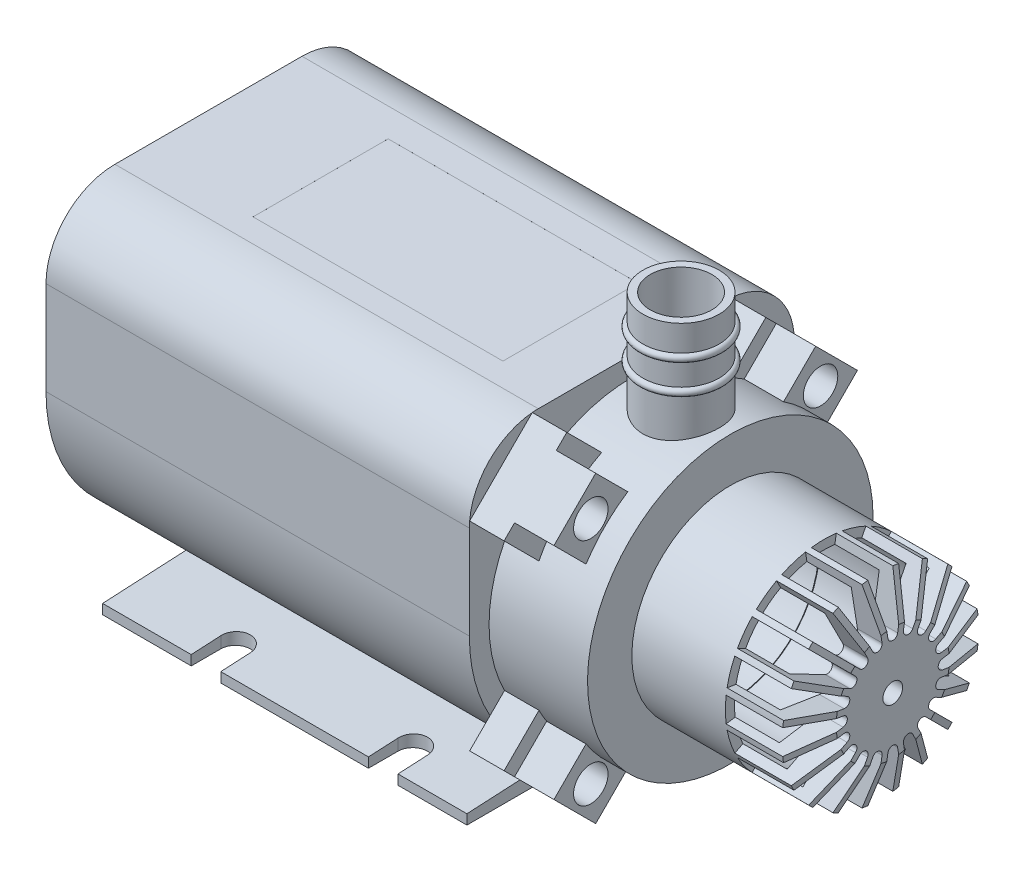
from build123d import *

# Parameters (mm, degrees)
BOSS_EXTRU_1_DEPTH           = 43
ESQUISSE2_R                  = 3.25
ENL_V_MAT_EXTRU_1_DEPTH      = 8
ESQUISSE3_R                  = 14.5
ESQUISSE3_R_2                = 9
BOSS_EXTRU_2_DEPTH           = 10
ESQUISSE4_R                  = 10
BOSS_EXTRU_3_DEPTH           = 16.5
ESQUISSE7_R                  = 1
ENL_V_MAT_EXTRU_2_DEPTH      = 10
ENL_V_MAT_EXTRU_3_DEPTH      = 7
ESQUISSE10_R                 = 9.079731565
ENL_V_MAT_EXTRU_4_DEPTH      = 14
BOSS_EXTRU_4_DEPTH           = 37
ENL_V_MAT_EXTRU_5_REACH      = 84.412
BOSS_EXTRU_5_DEPTH           = 3.5
BOSS_EXTRU_6_DEPTH           = 4
ESQUISSE16_R                 = 1.75
ENL_V_MAT_EXTRU_6_DEPTH      = 3
R_P_TITION_CIRCULAIRE1_COUNT = 4
ESQUISSE17_R                 = 13.283014913
ENL_V_MAT_EXTRU_7_DEPTH      = 31
ESQUISSE18_W                 = 25.376339854
ESQUISSE18_H                 = 13.72140852
ENL_V_MAT_EXTRU_8_DEPTH      = 0.001
ESQUISSE19_W                 = 1.346153846
ESQUISSE19_H                 = 0.358974359
ENL_V_MAT_EXTRU_9_DEPTH      = 0.01
ESQUISSE20_R                 = 2
ENL_V_MAT_EXTRU_10_DEPTH     = 0.01


with BuildPart() as part:
    # Esquisse1 → Boss.-Extru.1 (new body)
    with BuildSketch(Plane(origin=(0, 0, 0), x_dir=(0, 0, -1), z_dir=(1, 0, 0))):
        with BuildLine():
            Line((-16.5, 0), (-16.5, 9.5))
            ThreePointArc((-16.5, 9.5), (-14.449747468, 14.449747468), (-9.5, 16.5))
            Line((-9.5, 16.5), (9.5, 16.5))
            ThreePointArc((9.5, 16.5), (14.449747468, 14.449747468), (16.5, 9.5))
            Line((16.5, 9.5), (16.5, 0))
            ThreePointArc((16.5, 0), (0, -16.5), (-16.5, 0))
        make_face()
    extrude(amount=BOSS_EXTRU_1_DEPTH)

    # Esquisse2 → Enlèv. mat.-Extru.1 (cut)
    with BuildSketch(Plane.ZY):
        with Locations((0, -6.5)):
            Circle(ESQUISSE2_R)
    extrude(amount=-ENL_V_MAT_EXTRU_1_DEPTH, mode=Mode.SUBTRACT)

    # Esquisse3 → Boss.-Extru.2 (add)
    with BuildSketch(Plane(origin=(43, 0, 0), x_dir=(0, 0, -1), z_dir=(1, 0, 0))):
        Circle(ESQUISSE3_R)
        Circle(ESQUISSE3_R_2, mode=Mode.SUBTRACT)
    extrude(amount=BOSS_EXTRU_2_DEPTH)

    # Esquisse4 → Boss.-Extru.3 (add)
    with BuildSketch(Plane(origin=(53, 0, 0), x_dir=(0, 0, -1), z_dir=(1, 0, 0))):
        Circle(ESQUISSE4_R)
    extrude(amount=BOSS_EXTRU_3_DEPTH)

    # Esquisse6 → Révolution1 (revolve)
    with BuildSketch(Plane.XY):
        with BuildLine():
            Line((51.875, 10), (51.875, 18.125))
            ThreePointArc((51.875, 18.125), (52.25, 18.5), (51.875, 18.875))
            Line((51.875, 18.875), (51.875, 21.125))
            ThreePointArc((51.875, 21.125), (52.25, 21.5), (51.875, 21.875))
            Line((51.875, 21.875), (51.875, 24.5))
            Line((51.875, 24.5), (51.125, 24.5))
            Line((51.125, 24.5), (51.125, 10))
            Line((51.125, 10), (51.875, 10))
        make_face()
    revolve(axis=Axis((48, -3.633595293, 0), (0, 1, 0)))

    # Esquisse7 → Enlèv. mat.-Extru.2 (cut)
    with BuildSketch(Plane(origin=(69.5, 0, 0), x_dir=(0, 0, -1), z_dir=(1, 0, 0))):
        Circle(ESQUISSE7_R)
    extrude(amount=-ENL_V_MAT_EXTRU_2_DEPTH, mode=Mode.SUBTRACT)

    # Esquisse8 → Enlèv. mat.-Extru.3 (cut)
    with BuildSketch(Plane(origin=(69.5, 0, 0), x_dir=(0, 0, -1), z_dir=(1, 0, 0))):
        with BuildLine():
            Line((-9.384278831, 4.444831018), (-4.636672183, 2.025804607))
            ThreePointArc((-4.636672183, 2.025804607), (-4.388139175, 1.425792848), (-4.941884666, 1.086457175))
            Line((-4.941884666, 1.086457175), (-10.204647176, 1.919996869))
            ThreePointArc((-10.204647176, 1.919996869), (-9.87548492, 3.20873956), (-9.384278831, 4.444831018))
        make_face()
        with BuildLine():
            Line((-10.298507855, 1.327383865), (-5.035745345, 0.49384417))
            ThreePointArc((-5.035745345, 0.49384417), (-4.613962577, 0), (-5.035745345, -0.49384417))
            Line((-5.035745345, -0.49384417), (-10.298507855, -1.327383865))
            ThreePointArc((-10.298507855, -1.327383865), (-10.383699339, 0), (-10.298507855, 1.327383865))
        make_face()
        with BuildLine():
            Line((-7.551451211, 7.127187143), (-3.783729243, 3.359465174))
            ThreePointArc((-3.783729243, 3.359465174), (-3.732774136, 2.712019158), (-4.364277883, 2.560408522))
            Line((-4.364277883, 2.560408522), (-9.111884531, 4.979434933))
            ThreePointArc((-9.111884531, 4.979434933), (-8.40058923, 6.103385336), (-7.551451211, 7.127187143))
        make_face()
        with BuildLine():
            Line((-4.979434933, 9.111884531), (-2.560408522, 4.364277883))
            ThreePointArc((-2.560408522, 4.364277883), (-2.712019158, 3.732774136), (-3.359465174, 3.783729243))
            Line((-3.359465174, 3.783729243), (-7.127187143, 7.551451211))
            ThreePointArc((-7.127187143, 7.551451211), (-6.103385336, 8.40058923), (-4.979434933, 9.111884531))
        make_face()
        with BuildLine():
            Line((-1.919996869, 10.204647176), (-1.086457175, 4.941884666))
            ThreePointArc((-1.086457175, 4.941884666), (-1.425792848, 4.388139175), (-2.025804607, 4.636672183))
            Line((-2.025804607, 4.636672183), (-4.444831018, 9.384278831))
            ThreePointArc((-4.444831018, 9.384278831), (-3.20873956, 9.87548492), (-1.919996869, 10.204647176))
        make_face()
        with BuildLine():
            Line((1.327383865, 10.298507855), (0.49384417, 5.035745345))
            ThreePointArc((0.49384417, 5.035745345), (0, 4.613962577), (-0.49384417, 5.035745345))
            Line((-0.49384417, 5.035745345), (-1.327383865, 10.298507855))
            ThreePointArc((-1.327383865, 10.298507855), (0, 10.383699339), (1.327383865, 10.298507855))
        make_face()
        with BuildLine():
            Line((4.444831018, 9.384278831), (2.025804607, 4.636672183))
            ThreePointArc((2.025804607, 4.636672183), (1.425792848, 4.388139175), (1.086457175, 4.941884666))
            Line((1.086457175, 4.941884666), (1.919996869, 10.204647176))
            ThreePointArc((1.919996869, 10.204647176), (3.20873956, 9.87548492), (4.444831018, 9.384278831))
        make_face()
        with BuildLine():
            Line((7.127187143, 7.551451211), (3.359465174, 3.783729243))
            ThreePointArc((3.359465174, 3.783729243), (2.712019158, 3.732774136), (2.560408522, 4.364277883))
            Line((2.560408522, 4.364277883), (4.979434933, 9.111884531))
            ThreePointArc((4.979434933, 9.111884531), (6.103385336, 8.40058923), (7.127187143, 7.551451211))
        make_face()
        with BuildLine():
            Line((9.111884531, 4.979434933), (4.364277883, 2.560408522))
            ThreePointArc((4.364277883, 2.560408522), (3.732774136, 2.712019158), (3.783729243, 3.359465174))
            Line((3.783729243, 3.359465174), (7.551451211, 7.127187143))
            ThreePointArc((7.551451211, 7.127187143), (8.40058923, 6.103385336), (9.111884531, 4.979434933))
        make_face()
        with BuildLine():
            Line((10.204647176, 1.919996869), (4.941884666, 1.086457175))
            ThreePointArc((4.941884666, 1.086457175), (4.388139175, 1.425792848), (4.636672183, 2.025804607))
            Line((4.636672183, 2.025804607), (9.384278831, 4.444831018))
            ThreePointArc((9.384278831, 4.444831018), (9.87548492, 3.20873956), (10.204647176, 1.919996869))
        make_face()
        with BuildLine():
            Line((10.298507855, -1.327383865), (5.035745345, -0.49384417))
            ThreePointArc((5.035745345, -0.49384417), (4.613962577, 0), (5.035745345, 0.49384417))
            Line((5.035745345, 0.49384417), (10.298507855, 1.327383865))
            ThreePointArc((10.298507855, 1.327383865), (10.383699339, 0), (10.298507855, -1.327383865))
        make_face()
        with BuildLine():
            Line((9.384278831, -4.444831018), (4.636672183, -2.025804607))
            ThreePointArc((4.636672183, -2.025804607), (4.388139175, -1.425792848), (4.941884666, -1.086457175))
            Line((4.941884666, -1.086457175), (10.204647176, -1.919996869))
            ThreePointArc((10.204647176, -1.919996869), (9.87548492, -3.20873956), (9.384278831, -4.444831018))
        make_face()
        with BuildLine():
            Line((7.551451211, -7.127187143), (3.783729243, -3.359465174))
            ThreePointArc((3.783729243, -3.359465174), (3.732774136, -2.712019158), (4.364277883, -2.560408522))
            Line((4.364277883, -2.560408522), (9.111884531, -4.979434933))
            ThreePointArc((9.111884531, -4.979434933), (8.40058923, -6.103385336), (7.551451211, -7.127187143))
        make_face()
        with BuildLine():
            Line((4.979434933, -9.111884531), (2.560408522, -4.364277883))
            ThreePointArc((2.560408522, -4.364277883), (2.712019158, -3.732774136), (3.359465174, -3.783729243))
            Line((3.359465174, -3.783729243), (7.127187143, -7.551451211))
            ThreePointArc((7.127187143, -7.551451211), (6.103385336, -8.40058923), (4.979434933, -9.111884531))
        make_face()
        with BuildLine():
            Line((1.919996869, -10.204647176), (1.086457175, -4.941884666))
            ThreePointArc((1.086457175, -4.941884666), (1.425792848, -4.388139175), (2.025804607, -4.636672183))
            Line((2.025804607, -4.636672183), (4.444831018, -9.384278831))
            ThreePointArc((4.444831018, -9.384278831), (3.20873956, -9.87548492), (1.919996869, -10.204647176))
        make_face()
        with BuildLine():
            Line((-1.327383865, -10.298507855), (-0.49384417, -5.035745345))
            ThreePointArc((-0.49384417, -5.035745345), (0, -4.613962577), (0.49384417, -5.035745345))
            Line((0.49384417, -5.035745345), (1.327383865, -10.298507855))
            ThreePointArc((1.327383865, -10.298507855), (0, -10.383699339), (-1.327383865, -10.298507855))
        make_face()
        with BuildLine():
            Line((-4.444831018, -9.384278831), (-2.025804607, -4.636672183))
            ThreePointArc((-2.025804607, -4.636672183), (-1.425792848, -4.388139175), (-1.086457175, -4.941884666))
            Line((-1.086457175, -4.941884666), (-1.919996869, -10.204647176))
            ThreePointArc((-1.919996869, -10.204647176), (-3.20873956, -9.87548492), (-4.444831018, -9.384278831))
        make_face()
        with BuildLine():
            Line((-7.127187143, -7.551451211), (-3.359465174, -3.783729243))
            ThreePointArc((-3.359465174, -3.783729243), (-2.712019158, -3.732774136), (-2.560408522, -4.364277883))
            Line((-2.560408522, -4.364277883), (-4.979434933, -9.111884531))
            ThreePointArc((-4.979434933, -9.111884531), (-6.103385336, -8.40058923), (-7.127187143, -7.551451211))
        make_face()
        with BuildLine():
            Line((-9.111884531, -4.979434933), (-4.364277883, -2.560408522))
            ThreePointArc((-4.364277883, -2.560408522), (-3.732774136, -2.712019158), (-3.783729243, -3.359465174))
            Line((-3.783729243, -3.359465174), (-7.551451211, -7.127187143))
            ThreePointArc((-7.551451211, -7.127187143), (-8.40058923, -6.103385336), (-9.111884531, -4.979434933))
        make_face()
        with BuildLine():
            Line((-10.204647176, -1.919996869), (-4.941884666, -1.086457175))
            ThreePointArc((-4.941884666, -1.086457175), (-4.388139175, -1.425792848), (-4.636672183, -2.025804607))
            Line((-4.636672183, -2.025804607), (-9.384278831, -4.444831018))
            ThreePointArc((-9.384278831, -4.444831018), (-9.87548492, -3.20873956), (-10.204647176, -1.919996869))
        make_face()
    extrude(amount=-ENL_V_MAT_EXTRU_3_DEPTH, mode=Mode.SUBTRACT)

    # Esquisse9 → Enlèvement de matière-Révolution1 (revolve, cut)
    with BuildSketch(Plane.XY):
        Polygon((71.206200012, 0), (65.810405703, 18.181254274), (74.469280965, 15.75186294), (72.036322214, 0), align=None)
    revolve(axis=Axis((-2.259614813, 0, 0), (1, 0, 0)), mode=Mode.SUBTRACT)

    # Esquisse10 → Enlèv. mat.-Extru.4 (cut)
    with BuildSketch(Plane(origin=(53, 0, 0), x_dir=(0, 0, -1), z_dir=(1, 0, 0))):
        Circle(ESQUISSE10_R)
    extrude(amount=ENL_V_MAT_EXTRU_4_DEPTH, mode=Mode.SUBTRACT)

    # Esquisse11 → Boss.-Extru.4 (add)
    with BuildSketch(Plane(origin=(43, 0, 0), x_dir=(0, 0, -1), z_dir=(1, 0, 0))):
        Polygon((-16.75, -15.5), (0, -14.622169697), (16.75, -15.5), (16.75, -16.5), (-16.75, -16.5), align=None)
    extrude(amount=-BOSS_EXTRU_4_DEPTH)

    # Esquisse12 → Enlèv. mat.-Extru.5 (cut, up to next)
    with BuildSketch(Plane.XZ.offset(16.5), mode=Mode.PRIVATE) as enl_v_mat_extru_5_sk1:
        with BuildLine():
            Line((18, 13.75), (18, 17.75))
            Line((18, 17.75), (15, 17.75))
            Line((15, 17.75), (15, 13.75))
            ThreePointArc((15, 13.75), (16.5, 12.25), (18, 13.75))
        make_face()
    enl_v_mat_extru_5_tool1 = extrude(enl_v_mat_extru_5_sk1.sketch, amount=-ENL_V_MAT_EXTRU_5_REACH, mode=Mode.PRIVATE) & part.part
    # Esquisse12 → Enlèv. mat.-Extru.5 (cut, up to next)
    with BuildSketch(Plane.XZ.offset(16.5), mode=Mode.PRIVATE) as enl_v_mat_extru_5_sk2:
        with BuildLine():
            Line((18, -13.75), (18, -17.75))
            Line((18, -17.75), (15, -17.75))
            Line((15, -17.75), (15, -13.75))
            ThreePointArc((15, -13.75), (16.5, -12.25), (18, -13.75))
        make_face()
    enl_v_mat_extru_5_tool2 = extrude(enl_v_mat_extru_5_sk2.sketch, amount=-ENL_V_MAT_EXTRU_5_REACH, mode=Mode.PRIVATE) & part.part
    # Esquisse12 → Enlèv. mat.-Extru.5 (cut, up to next)
    with BuildSketch(Plane.XZ.offset(16.5), mode=Mode.PRIVATE) as enl_v_mat_extru_5_sk3:
        with BuildLine():
            Line((36, 13.75), (36, 17.75))
            Line((36, 17.75), (33, 17.75))
            Line((33, 17.75), (33, 13.75))
            ThreePointArc((33, 13.75), (34.5, 12.25), (36, 13.75))
        make_face()
    enl_v_mat_extru_5_tool3 = extrude(enl_v_mat_extru_5_sk3.sketch, amount=-ENL_V_MAT_EXTRU_5_REACH, mode=Mode.PRIVATE) & part.part
    # Esquisse12 → Enlèv. mat.-Extru.5 (cut, up to next)
    with BuildSketch(Plane.XZ.offset(16.5), mode=Mode.PRIVATE) as enl_v_mat_extru_5_sk4:
        with BuildLine():
            Line((33, -13.75), (33, -17.75))
            Line((33, -17.75), (36, -17.75))
            Line((36, -17.75), (36, -13.75))
            ThreePointArc((36, -13.75), (34.5, -12.25), (33, -13.75))
        make_face()
    enl_v_mat_extru_5_tool4 = extrude(enl_v_mat_extru_5_sk4.sketch, amount=-ENL_V_MAT_EXTRU_5_REACH, mode=Mode.PRIVATE) & part.part
    add(enl_v_mat_extru_5_tool1.solids().sort_by_distance((16.5, -16.5, 15.150128))[0], mode=Mode.SUBTRACT)
    add(enl_v_mat_extru_5_tool2.solids().sort_by_distance((16.5, -16.5, -15.150128))[0], mode=Mode.SUBTRACT)
    add(enl_v_mat_extru_5_tool3.solids().sort_by_distance((34.5, -16.5, 15.150128))[0], mode=Mode.SUBTRACT)
    add(enl_v_mat_extru_5_tool4.solids().sort_by_distance((34.5, -16.5, -15.150128))[0], mode=Mode.SUBTRACT)

    # Esquisse13 → Boss.-Extru.5 (add)
    with BuildSketch(Plane(origin=(43, 0, 0), x_dir=(0, 0, -1), z_dir=(1, 0, 0))):
        Polygon((10.109457207, 16.473418237), (16.473418237, 10.109457207), (12.751363253, 6.387402222), (6.387402222, 12.751363253), align=None)
    boss_extru_5 = extrude(amount=BOSS_EXTRU_5_DEPTH)

    # Esquisse15 → Boss.-Extru.6 (add)
    with BuildSketch(Plane(origin=(46.5, 0, 0), x_dir=(0, 0, -1), z_dir=(1, 0, 0))):
        Polygon((11.170117378, 15.412758066), (7.484521476, 11.727162163), (11.715659493, 7.473018806), (15.412758066, 11.170117378), align=None)
    boss_extru_6 = extrude(amount=BOSS_EXTRU_6_DEPTH)

    # Esquisse16 → Enlèv. mat.-Extru.6 (cut)
    with BuildSketch(Plane(origin=(50.5, 0, 0), x_dir=(0, 0, -1), z_dir=(1, 0, 0))):
        with Locations((11.66726189, 11.66726189)):
            Circle(ESQUISSE16_R)
    enl_v_mat_extru_6 = extrude(amount=-ENL_V_MAT_EXTRU_6_DEPTH, mode=Mode.SUBTRACT)

    # Répétition circulaire1: Boss.-Extru.5, Boss.-Extru.6, Enlèv. mat.-Extru.6 ×4 about axis
    r_p_tition_circulaire1_axis = Axis((43, 0, 0), (-1, 0, 0))
    add([boss_extru_5.rotate(r_p_tition_circulaire1_axis, i * 360 / R_P_TITION_CIRCULAIRE1_COUNT) for i in range(1, R_P_TITION_CIRCULAIRE1_COUNT)])
    add([boss_extru_6.rotate(r_p_tition_circulaire1_axis, i * 360 / R_P_TITION_CIRCULAIRE1_COUNT) for i in range(1, R_P_TITION_CIRCULAIRE1_COUNT)])
    add([enl_v_mat_extru_6.rotate(r_p_tition_circulaire1_axis, i * 360 / R_P_TITION_CIRCULAIRE1_COUNT) for i in range(1, R_P_TITION_CIRCULAIRE1_COUNT)], mode=Mode.SUBTRACT)

    # Esquisse17 → Enlèv. mat.-Extru.7 (cut)
    with BuildSketch(Plane(origin=(43, 0, 0), x_dir=(0, 0, -1), z_dir=(1, 0, 0))):
        Circle(ESQUISSE17_R)
    extrude(amount=-ENL_V_MAT_EXTRU_7_DEPTH, mode=Mode.SUBTRACT)

    # Esquisse18 → Enlèv. mat.-Extru.8 (cut)
    with BuildSketch(Plane(origin=(0, 16.5, 0), x_dir=(1, 0, 0), z_dir=(0, 1, 0))):
        with Locations((24.327947405, -0.247977262)):
            Rectangle(ESQUISSE18_W, ESQUISSE18_H)
    extrude(amount=-ENL_V_MAT_EXTRU_8_DEPTH, mode=Mode.SUBTRACT)

    # Esquisse19 → Enlèv. mat.-Extru.9 (cut)
    with BuildSketch(Plane.ZY):
        with Locations((4.201507301, 10.144306079)):
            Rectangle(ESQUISSE19_W, ESQUISSE19_H)
        Polygon((5.887705218, 12.298152232), (6.534840634, 12.298152232), (6.534840634, 8.798152232), (6.22073807, 8.798152232), (6.22073807, 11.939177873), (5.682276532, 11.939177873), align=None)
        Polygon((8.58001291, 12.298152232), (9.227148327, 12.298152232), (9.227148327, 8.798152232), (8.913045763, 8.798152232), (8.913045763, 11.939177873), (8.374584224, 11.939177873), align=None)
    extrude(amount=-ENL_V_MAT_EXTRU_9_DEPTH, mode=Mode.SUBTRACT)

    # Esquisse20 → Enlèv. mat.-Extru.10 (cut)
    with BuildSketch(Plane.ZY):
        with Locations((10, 0)):
            Circle(ESQUISSE20_R)
    extrude(amount=-ENL_V_MAT_EXTRU_10_DEPTH, mode=Mode.SUBTRACT)


solid = part.part
